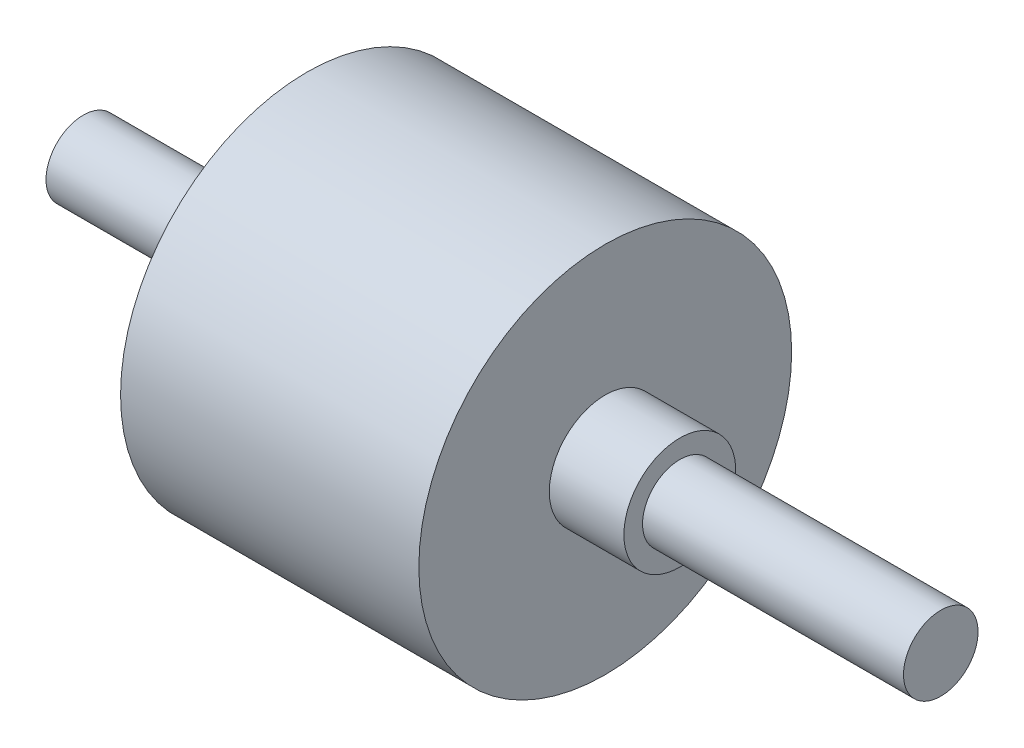
from build123d import *


with BuildPart() as part:
    # Sketch1 → Revolve1 (revolve)
    with BuildSketch(Plane(origin=(0, 0, 0), x_dir=(1, 0, 0), z_dir=(0, 1, 0))):
        Polygon((0, 0), (0, 5), (30, 5), (30, 25), (70, 25), (70, 7.5), (80, 7.5), (80, 5), (115, 5), (115, 0), align=None)
    revolve(axis=Axis((0, 0, 0), (1, 0, 0)))


solid = part.part
